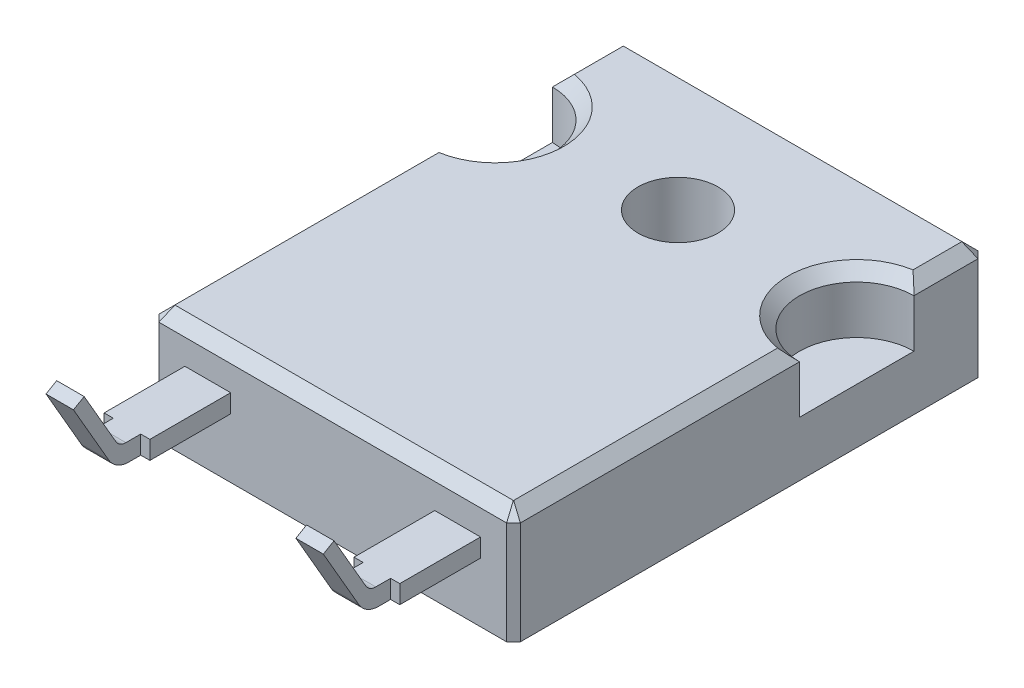
from build123d import *

# Parameters (mm, degrees)
SKETCH_1_R          = 1.75
EXTRUDE_1_DEPTH     = 2.6
EXTRUDE_START       = -2.4
SKETCH_1_3_W        = 15.8
SKETCH_1_3_H        = 20.6
SKETCH_1_3_R        = 1.75
EXTRUDE_2_DEPTH     = 2.4
EXTRUDE_START_2     = 0.2
EXTRUDE_3_DEPTH     = 0.8
EXTRUDE_3_2_DEPTH   = 0.8
CHAMFER_1_SIZE      = 0.3
CHAMFER_2_SIZE      = 0.5
SKETCH_2_W          = 13.8
SKETCH_2_H          = 18.6
SKETCH_2_R          = 1.75
CUT_EXTRUDE_1_DEPTH = 1.5
SKETCH_3_W          = 1.2
SKETCH_3_H          = 0.54
EXTRUDE_6_DEPTH     = 3.68
FILLET_1_R          = 1
FILLET_2_R          = 1
FILLET_3_R          = 0.5
FILLET_4_R          = 0.5


with BuildPart() as part:
    # Эскиз1 → Бобышка-Вытянуть1 (new body)
    with BuildSketch(Plane(origin=(0, 0, 0), x_dir=(1, 0, 0), z_dir=(0, 1, 0))):
        with BuildLine():
            Line((6.46, -10.3), (7.9, -10.3))
            Line((7.9, -10.3), (7.9, 2.2))
            ThreePointArc((7.9, 2.2), (5.4, 4.7), (7.9, 7.2))
            Line((7.9, 7.2), (7.9, 10.3))
            Line((7.9, 10.3), (-7.9, 10.3))
            Line((-7.9, 10.3), (-7.9, 7.2))
            ThreePointArc((-7.9, 7.2), (-5.4, 4.7), (-7.9, 2.2))
            Line((-7.9, 2.2), (-7.9, -10.3))
            Line((-7.9, -10.3), (-6.46, -10.3))
            Line((-6.46, -10.3), (-4.46, -10.3))
            Line((-4.46, -10.3), (4.46, -10.3))
            Line((4.46, -10.3), (6.46, -10.3))
        make_face()
        with Locations((0, 4.79)):
            Circle(SKETCH_1_R, mode=Mode.SUBTRACT)
    extrude(amount=EXTRUDE_1_DEPTH)

    # Эскиз1<3> → Бобышка-Вытянуть2 (add)
    with BuildSketch(Plane(origin=(0, 0, 0), x_dir=(1, 0, 0), z_dir=(0, 1, 0)).offset(EXTRUDE_START)):
        Rectangle(SKETCH_1_3_W, SKETCH_1_3_H)
        with Locations((0, 4.79)):
            Circle(SKETCH_1_3_R, mode=Mode.SUBTRACT)
    extrude(amount=EXTRUDE_2_DEPTH)

    # Фаска1
    chamfer_1_edges = [part.edges().sort_by_distance(p)[0] for p in [
        (-7.9, 0.1, 10.3),
        (-7.9, 0.1, -10.3),
        (7.9, 0.1, -10.3),
        (7.9, 0.1, 10.3),
    ]]
    chamfer(chamfer_1_edges, length=CHAMFER_1_SIZE)

    # Фаска2
    chamfer_2_edges = [part.edges().sort_by_distance(p)[0] for p in [
        (-5.4, 2.6, -4.7),
        (-7.9, 2.6, -8.6),
        (-7.75, 2.6, -10.15),
        (0, 2.6, -10.3),
        (7.75, 2.6, -10.15),
        (7.9, 2.6, -8.6),
        (5.4, 2.6, -4.7),
        (7.9, 2.6, 3.9),
        (7.75, 2.6, 10.15),
        (0, 2.6, 10.3),
        (-7.75, 2.6, 10.15),
        (-7.9, 2.6, 3.9),
    ]]
    chamfer(chamfer_2_edges, length=CHAMFER_2_SIZE)

    # Эскиз2 → Вырез-Вытянуть1 (cut)
    with BuildSketch(Plane.XZ.offset(2.4)):
        Rectangle(SKETCH_2_W, SKETCH_2_H)
        with Locations((0, -4.79)):
            Circle(SKETCH_2_R, mode=Mode.SUBTRACT)
    extrude(amount=-CUT_EXTRUDE_1_DEPTH, mode=Mode.SUBTRACT)


with BuildPart() as body_2:
    # Эскиз1<4> → Бобышка-Вытянуть3 (new body)
    with BuildSketch(Plane(origin=(0, 0, 0), x_dir=(1, 0, 0), z_dir=(0, 1, 0)).offset(EXTRUDE_START_2)):
        Polygon((6.46, -13.83), (6.46, -10.3), (4.46, -10.3), (4.46, -13.83), (4.86, -13.83), (4.86, -14.93), (6.06, -14.93), (6.06, -13.83), align=None)
    extrude(amount=EXTRUDE_3_DEPTH)



with BuildPart() as body_3:
    # Эскиз1<4> → Extrude 3 2 (new body)
    with BuildSketch(Plane(origin=(0, 0, 0), x_dir=(1, 0, 0), z_dir=(0, 1, 0)).offset(EXTRUDE_START_2)):
        Polygon((-4.46, -13.83), (-4.46, -10.3), (-6.46, -10.3), (-6.46, -13.83), (-6.06, -13.83), (-6.06, -14.93), (-4.86, -14.93), (-4.86, -13.83), align=None)
    extrude(amount=EXTRUDE_3_2_DEPTH)


with BuildPart() as body_2_1:
    add(body_2.part)

    add(body_3.part)  # Бобышка-Вытянуть6 merges body 3
    # Эскиз3 → Бобышка-Вытянуть6 (add)
    with BuildSketch(Plane(origin=(0, 6.614879639, 3.81910254), x_dir=(1, 0, 0), z_dir=(0, -0.866025403784438, -0.500000000000001))):
        with Locations((-5.46, 12.559759279)):
            Rectangle(SKETCH_3_W, SKETCH_3_H)
        with Locations((5.46, 12.559759279)):
            Rectangle(SKETCH_3_W, SKETCH_3_H)
    extrude(amount=-EXTRUDE_6_DEPTH)

    # Скругление1
    fillet_1_edges = [body_2_1.edges().sort_by_distance(p)[0] for p in [
        (-5.46, 0.2, 14.93),
    ]]
    fillet(fillet_1_edges, radius=FILLET_1_R)

    # Скругление2
    fillet_2_edges = [body_2_1.edges().sort_by_distance(p)[0] for p in [
        (5.46, 0.2, 14.93),
    ]]
    fillet(fillet_2_edges, radius=FILLET_2_R)

    # Скругление3
    fillet_3_edges = [body_2_1.edges().sort_by_distance(p)[0] for p in [
        (5.46, 1, 14.768341925),
    ]]
    fillet(fillet_3_edges, radius=FILLET_3_R)

    # Скругление4
    fillet_4_edges = [body_2_1.edges().sort_by_distance(p)[0] for p in [
        (-5.46, 1, 14.768341925),
    ]]
    fillet(fillet_4_edges, radius=FILLET_4_R)


solid = Compound([part.part, body_2_1.part])
